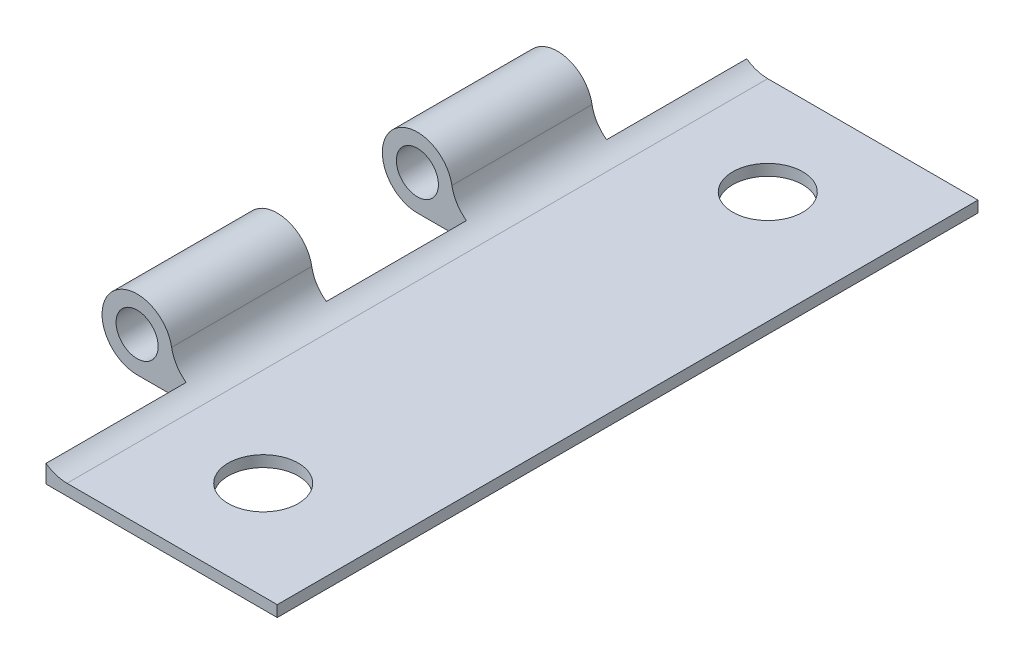
from build123d import *

# Parameters (mm, degrees)
ESBO_O1_R                = 1.5
RESSALTO_EXTRUS_O1_DEPTH = 50
ESBO_O2_R                = 2.5
ESBO_O2_W                = 6
ESBO_O2_H                = 10
CORTE_EXTRUS_O2_DEPTH    = 6


with BuildPart() as part:
    # Esboço1 → Ressalto-extrusão1 (new body)
    with BuildSketch(Plane.XY):
        with BuildLine():
            Line((0, 0), (-20, 0))
            ThreePointArc((-20, 0), (-22.324602514, 3.419903881), (-18.2892713, 4.32302148))
            ThreePointArc((-18.2892713, 4.32302148), (-17.800459182, 3.688284557), (-17.537523452, 2.9315197))
            ThreePointArc((-17.537523452, 2.9315197), (-16.656985327, 1.403588896), (-15, 0.8))
            Line((-15, 0.8), (0, 0.8))
            Line((0, 0.8), (0, 0))
        make_face()
        with Locations((-20, 2.5)):
            Circle(ESBO_O1_R, mode=Mode.SUBTRACT)
    extrude(amount=RESSALTO_EXTRUS_O1_DEPTH)

    # Esboço2 → Corte-extrusão2 (cut, through all)
    with BuildSketch(Plane.XZ):
        with Locations((-8, 43)):
            Circle(ESBO_O2_R)
        with Locations((-8, 7)):
            Circle(ESBO_O2_R)
        with Locations((-19.5, 5)):
            Rectangle(ESBO_O2_W, ESBO_O2_H)
        with Locations((-19.5, 25)):
            Rectangle(ESBO_O2_W, ESBO_O2_H)
        with Locations((-19.5, 45)):
            Rectangle(ESBO_O2_W, ESBO_O2_H)
    extrude(amount=-CORTE_EXTRUS_O2_DEPTH, mode=Mode.SUBTRACT)


solid = part.part
